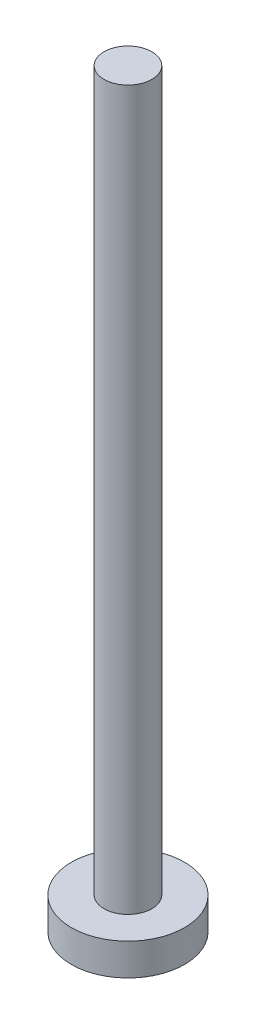
from build123d import *

# Parameters (mm, degrees)
SKETCH_1_R      = 3.55
EXTRUDE_1_DEPTH = 2
SKETCH_2_R      = 1.5
EXTRUDE_2_DEPTH = 45


with BuildPart() as part:
    # 草图1 → 凸台-拉伸1 (new body)
    with BuildSketch(Plane(origin=(0, 0, 0), x_dir=(1, 0, 0), z_dir=(0, 1, 0))):
        Circle(SKETCH_1_R)
    extrude(amount=EXTRUDE_1_DEPTH)

    # 草图2 → 凸台-拉伸2 (add)
    with BuildSketch(Plane(origin=(0, 2, 0), x_dir=(1, 0, 0), z_dir=(0, 1, 0))):
        Circle(SKETCH_2_R)
    extrude(amount=EXTRUDE_2_DEPTH)


solid = part.part
